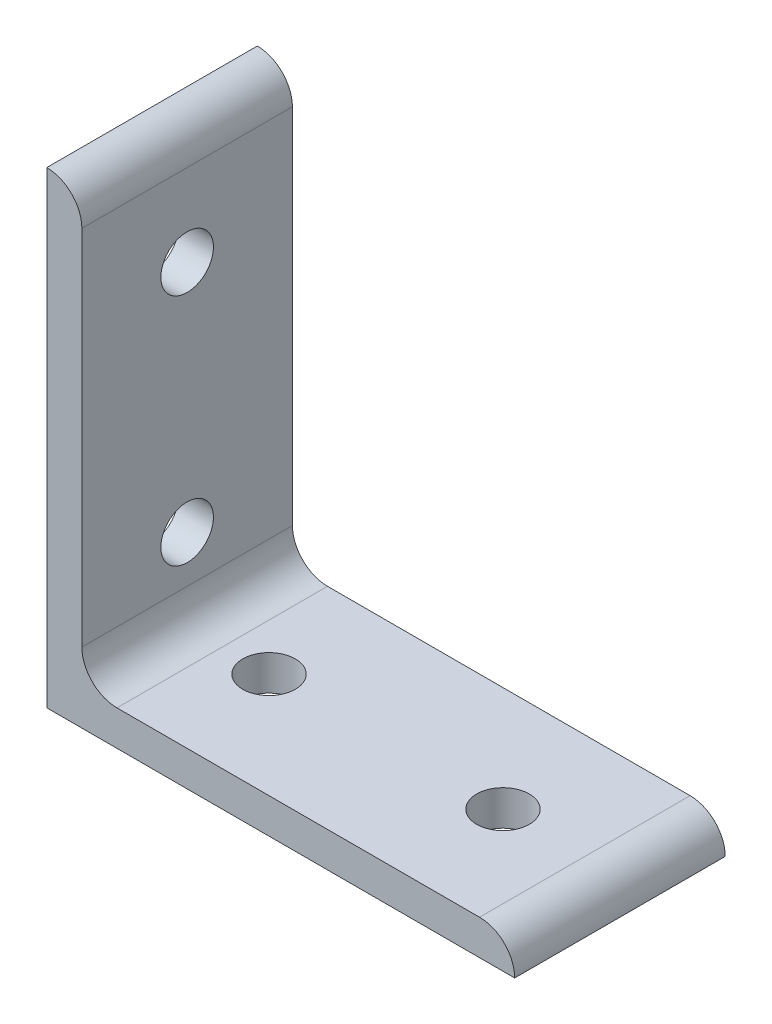
from build123d import *

# Parameters (mm, degrees)
BOSS_EXTRUDE1_DEPTH = 18
SKETCH2_R           = 4.5
CUT_EXTRUDE1_DEPTH  = 81
SKETCH3_R           = 4.5
CUT_EXTRUDE2_DEPTH  = 81


with BuildPart() as part:
    # Sketch1 → Boss-Extrude1 (new body, symmetric)
    with BuildSketch(Plane.XY):
        with BuildLine():
            Line((0, 0), (0, 80))
            ThreePointArc((0, 80), (4.242640687, 78.242640687), (6, 74))
            Line((6, 74), (6, 12))
            ThreePointArc((6, 12), (7.757359313, 7.757359313), (12, 6))
            Line((12, 6), (74, 6))
            ThreePointArc((74, 6), (78.242640687, 4.242640687), (80, 0))
            Line((80, 0), (0, 0))
        make_face()
    extrude(amount=BOSS_EXTRUDE1_DEPTH, both=True)

    # Sketch2 → Cut-Extrude1 (cut, through all)
    with BuildSketch(Plane(origin=(0, 0, 0), x_dir=(1, 0, 0), z_dir=(0, 1, 0))):
        with Locations((20, 0)):
            Circle(SKETCH2_R)
        with Locations((60, 0)):
            Circle(SKETCH2_R)
    extrude(amount=CUT_EXTRUDE1_DEPTH, mode=Mode.SUBTRACT)

    # Sketch3 → Cut-Extrude2 (cut, through all)
    with BuildSketch(Plane(origin=(0, 0, 0), x_dir=(0, 0, -1), z_dir=(1, 0, 0))):
        with Locations((0, 20)):
            Circle(SKETCH3_R)
        with Locations((0, 60)):
            Circle(SKETCH3_R)
    extrude(amount=CUT_EXTRUDE2_DEPTH, mode=Mode.SUBTRACT)


solid = part.part
